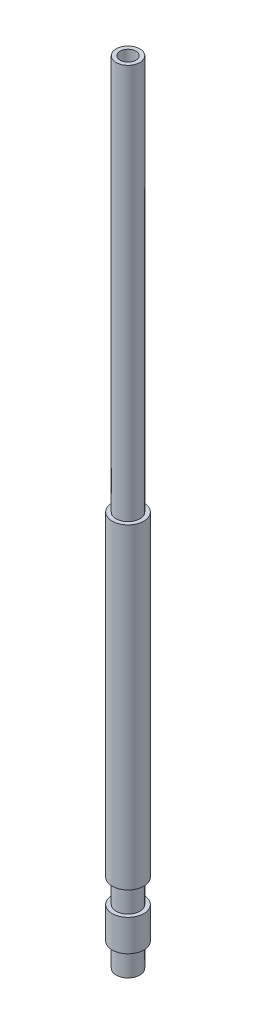
from build123d import *

# Parameters (mm, degrees)
SKETCH_1_R      = 2
SKETCH_1_R_2    = 1
EXTRUDE_1_DEPTH = 100
SKETCH_2_W      = 0.5
SKETCH_2_H      = 3
SKETCH_4_W      = 0.5
SKETCH_4_H      = 50


with BuildPart() as part:
    # Эскиз1 → Бобышка-Вытянуть1 (new body)
    with BuildSketch(Plane(origin=(0, 0, 0), x_dir=(1, 0, 0), z_dir=(0, 1, 0))):
        Circle(SKETCH_1_R)
        Circle(SKETCH_1_R_2, mode=Mode.SUBTRACT)
    extrude(amount=EXTRUDE_1_DEPTH)

    # Эскиз2 → Вырез-Повернуть1 (revolve, cut)
    with BuildSketch(Plane.XY):
        with Locations((1.75, 1.5)):
            Rectangle(SKETCH_2_W, SKETCH_2_H)
        with Locations((1.75, 8.5)):
            Rectangle(SKETCH_2_W, SKETCH_2_H)
    revolve(axis=Axis((0, 0, 0), (0, 1, 0)), mode=Mode.SUBTRACT)

    # Эскиз4 → Вырез-Повернуть2 (revolve, cut)
    with BuildSketch(Plane.XY):
        with Locations((1.75, 75)):
            Rectangle(SKETCH_4_W, SKETCH_4_H)
    revolve(axis=Axis((0, 0, 0), (0, 1, 0)), mode=Mode.SUBTRACT)


solid = part.part
